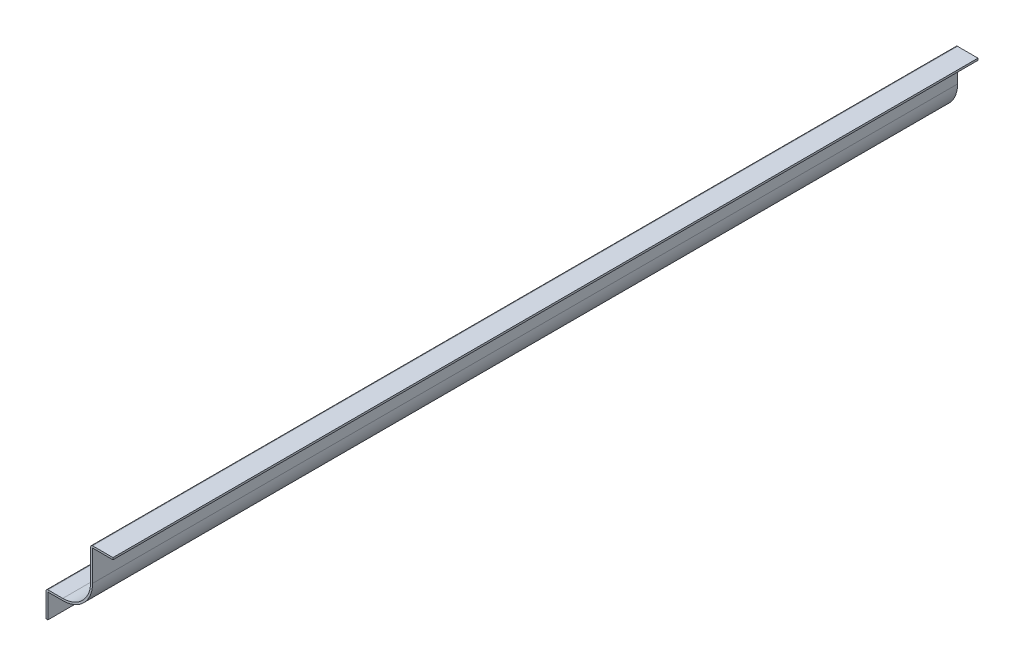
from build123d import *

# Parameters (mm, degrees)
EXTRUDE_THIN1_DEPTH = 738.1875
FILLET1_R           = 1.651


with BuildPart() as part:
    # Sketch1 → Extrude-Thin1 (new body)
    with BuildSketch(Plane.XY):
        with BuildLine():
            Line((0, 0), (0, 22.225))
            Line((0, 22.225), (14.2875, 22.225))
            ThreePointArc((14.2875, 22.225), (31.125480227, 29.199519773), (38.1, 46.0375))
            Line((38.1, 46.0375), (38.1, 73.81875))
            Line((38.1, 73.81875), (57.15, 73.81875))
            Line((57.15, 73.81875), (57.15, 72.16775))
            Line((57.15, 72.16775), (39.751, 72.16775))
            Line((39.751, 72.16775), (39.751, 46.0375))
            ThreePointArc((39.751, 46.0375), (32.292913523, 28.032086477), (14.2875, 20.574))
            Line((14.2875, 20.574), (1.651, 20.574))
            Line((1.651, 20.574), (1.651, 0))
            Line((1.651, 0), (0, 0))
        make_face()
    extrude(amount=-EXTRUDE_THIN1_DEPTH)

    # Fillet1
    fillet1_edges = [part.edges().sort_by_distance(p)[0] for p in [
        (0, 22.225, -369.09375),
        (38.1, 73.81875, -369.09375),
    ]]
    fillet(fillet1_edges, radius=FILLET1_R)


solid = part.part
